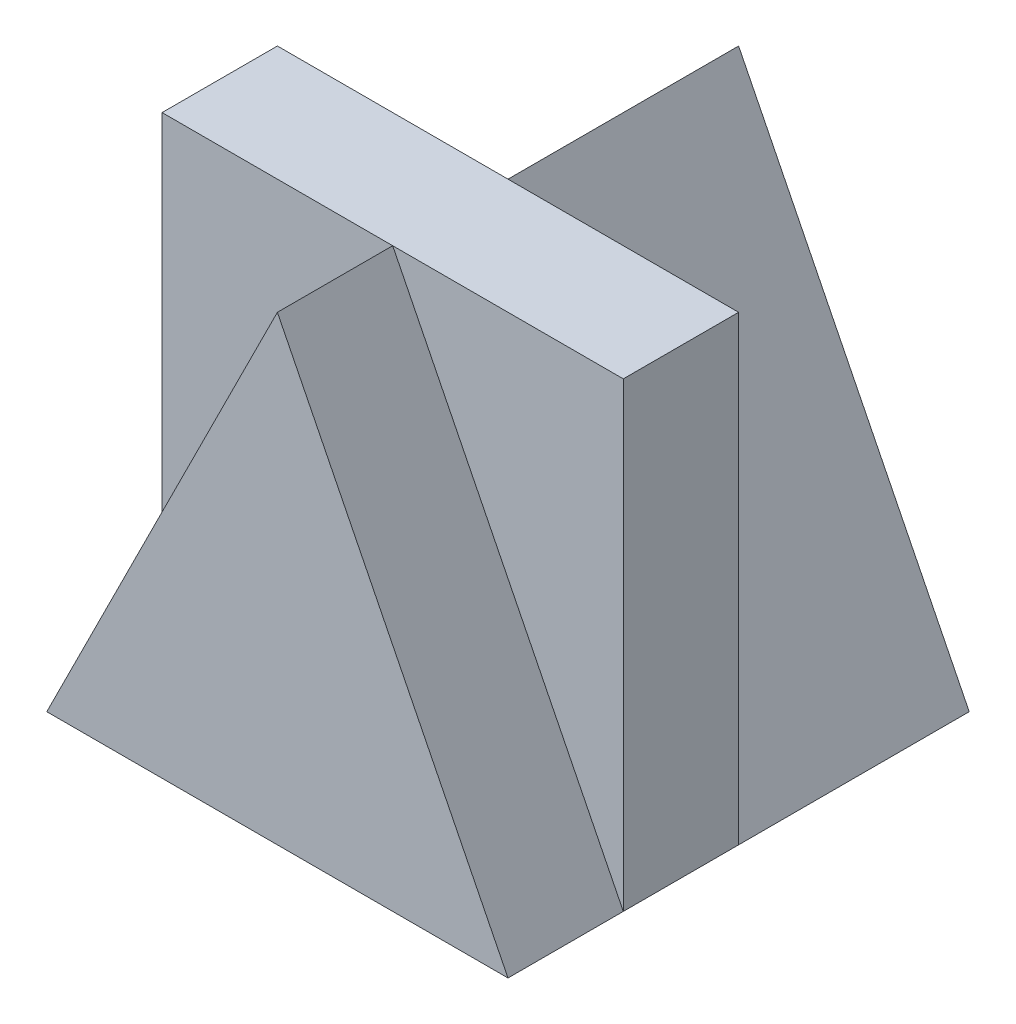
from build123d import *

# Parameters (mm, degrees)
SKETCH1_W           = 4
SKETCH1_H           = 4
BOSS_EXTRUDE1_DEPTH = 4
CUT_EXTRUDE3_DEPTH  = 1
CUT_EXTRUDE5_DEPTH  = 2


with BuildPart() as part:
    # Sketch1 → Boss-Extrude1 (new body)
    with BuildSketch(Plane(origin=(0, 0, 0), x_dir=(1, 0, 0), z_dir=(0, 1, 0))):
        Rectangle(SKETCH1_W, SKETCH1_H)
    extrude(amount=BOSS_EXTRUDE1_DEPTH)

    # Sketch6 → Cut-Extrude3 (cut)
    with BuildSketch(Plane.XY.offset(2)):
        Polygon((-2, 0), (0, 4), (-2, 4), align=None)
        Polygon((2, 4), (0, 4), (2, 0), align=None)
    extrude(amount=-CUT_EXTRUDE3_DEPTH, mode=Mode.SUBTRACT)

    # Sketch8 → Cut-Extrude5 (cut)
    with BuildSketch(Plane(origin=(0, 0, -2), x_dir=(-1, 0, 0), z_dir=(0, 0, -1))):
        Polygon((-2, 4), (-2, 0), (0, 4), align=None)
        Polygon((2, 4), (0, 4), (2, 0), align=None)
    extrude(amount=-CUT_EXTRUDE5_DEPTH, mode=Mode.SUBTRACT)


solid = part.part
